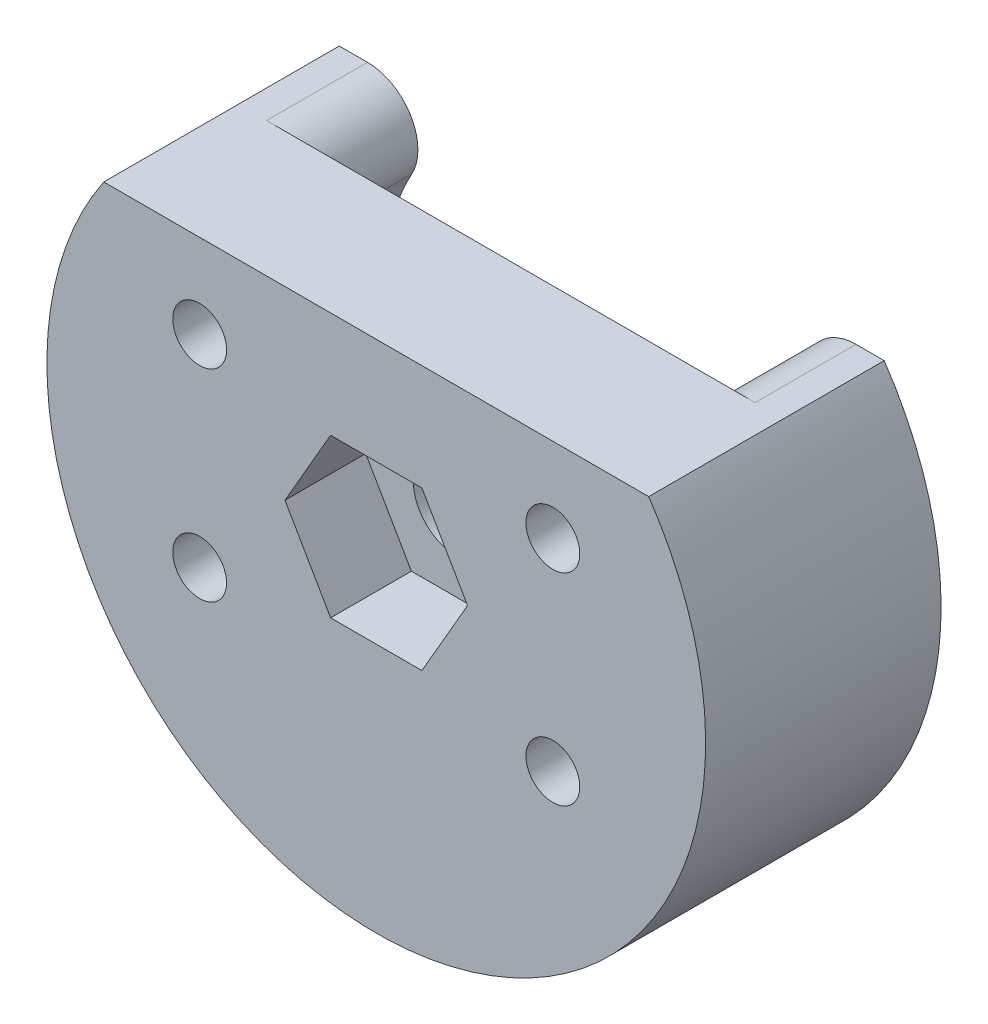
from build123d import *
from build123d.topology import SkipClean

# Parameters (mm, degrees)
SKETCH1_R           = 0.8
BOSS_EXTRUDE1_DEPTH = 4
CUT_EXTRUDE1_DEPTH  = 2.4
SKETCH3_R           = 1.3
CUT_EXTRUDE2_DEPTH  = 4
BOSS_EXTRUDE2_DEPTH = 3


with BuildPart() as part:
    # Sketch1 → Boss-Extrude1 (new body)
    with BuildSketch(Plane.XY):
        with BuildLine():
            Line((0, 12.5), (16.2, 12.5))
            ThreePointArc((16.2, 12.5), (8.1, -2.790812019), (0, 12.5))
        make_face()
        with Locations((2.85, 10)):
            Circle(SKETCH1_R, mode=Mode.SUBTRACT)
        with Locations(Location((13.35, 10, 0), (0, 0, 180))):
            Circle(SKETCH1_R, mode=Mode.SUBTRACT)
        with Locations(Location((13.35, 4, 0), (0, 0, 180))):
            Circle(SKETCH1_R, mode=Mode.SUBTRACT)
        with Locations((2.85, 4)):
            Circle(SKETCH1_R, mode=Mode.SUBTRACT)
    extrude(amount=BOSS_EXTRUDE1_DEPTH)

    # Sketch2 → Cut-Extrude1 (cut)
    with BuildSketch(Plane.XY.offset(4)):
        Polygon((10.813546265, 7), (9.456773133, 9.35), (6.743226867, 9.35), (5.386453735, 7), (6.743226867, 4.65), (9.456773133, 4.65), align=None)
    extrude(amount=-CUT_EXTRUDE1_DEPTH, mode=Mode.SUBTRACT)

    # Sketch3 → Cut-Extrude2 (cut)
    with BuildSketch(Plane.XY.offset(4)):
        with Locations((8.1, 7)):
            Circle(SKETCH3_R)
    extrude(amount=-CUT_EXTRUDE2_DEPTH, mode=Mode.SUBTRACT)

    # Sketch4 → Boss-Extrude2 (add)
    with SkipClean():  # the faces are left unmerged after this step: merging them gives an invalid solid
        with BuildSketch(Plane.XY):
            with BuildLine():
                Line((16.2, 12.5), (15.362063339, 12.5))
                ThreePointArc((15.362063339, 12.5), (14.070641831, 11.763040292), (14.048187812, 10.276307316))
                ThreePointArc((14.048187812, 10.276307316), (8.1, 0.209187981), (2.151812188, 10.276307316))
                ThreePointArc((2.151812188, 10.276307316), (2.129358169, 11.763040292), (0.837936661, 12.5))
                Line((0.837936661, 12.5), (0, 12.5))
                ThreePointArc((0, 12.5), (8.1, -2.790812019), (16.2, 12.5))
            make_face()
        extrude(amount=-BOSS_EXTRUDE2_DEPTH)


solid = part.part
